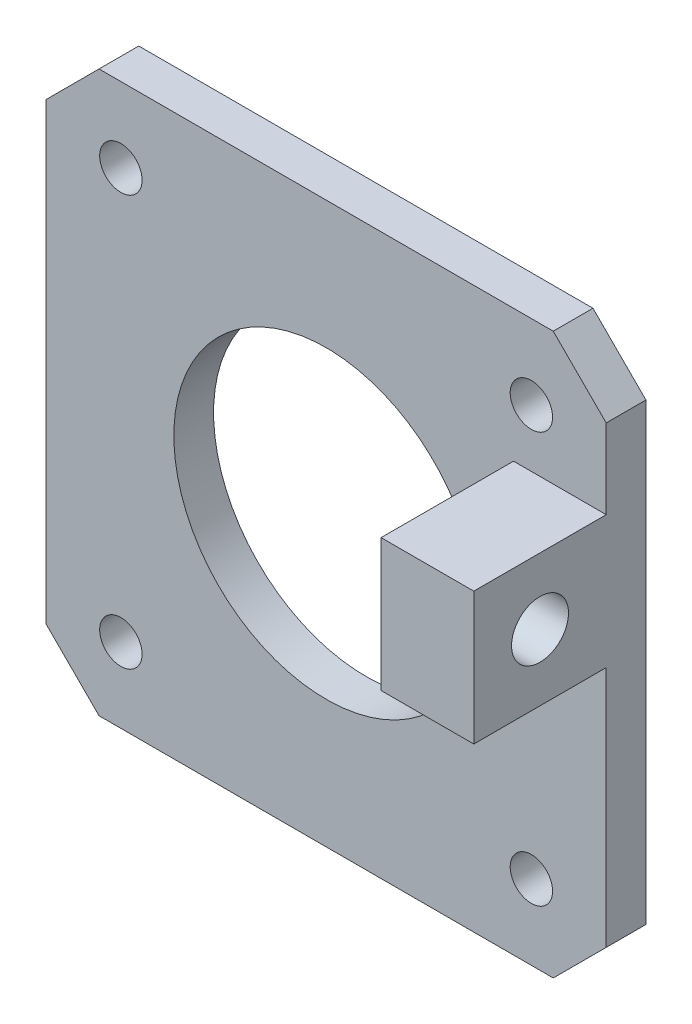
from build123d import *

# Parameters (mm, degrees)
CROQUIS1_R              = 11.5
CROQUIS1_R_2            = 1.6
SALIENTE_EXTRUIR1_DEPTH = 3
CROQUIS2_W              = 10
CROQUIS2_H              = 10
CROQUIS2_R              = 2.15
SALIENTE_EXTRUIR2_DEPTH = 7


with BuildPart() as part:
    # Croquis1 → Saliente-Extruir1 (new body)
    with BuildSketch(Plane.XY):
        Polygon((21.15, 17.15), (17.15, 21.15), (-17.15, 21.15), (-21.15, 17.15), (-21.15, -17.15), (-17.15, -21.15), (17.15, -21.15), (21.15, -17.15), align=None)
        Circle(CROQUIS1_R, mode=Mode.SUBTRACT)
        with Locations((15.5, 15.5)):
            Circle(CROQUIS1_R_2, mode=Mode.SUBTRACT)
        with Locations((15.5, -15.5)):
            Circle(CROQUIS1_R_2, mode=Mode.SUBTRACT)
        with Locations((-15.5, -15.5)):
            Circle(CROQUIS1_R_2, mode=Mode.SUBTRACT)
        with Locations((-15.5, 15.5)):
            Circle(CROQUIS1_R_2, mode=Mode.SUBTRACT)
    extrude(amount=SALIENTE_EXTRUIR1_DEPTH)

    # Croquis2 → Saliente-Extruir2 (add)
    with BuildSketch(Plane(origin=(21.15, 0, 0), x_dir=(0, 0, -1), z_dir=(1, 0, 0))):
        with Locations((-8, 6.15)):
            Rectangle(CROQUIS2_W, CROQUIS2_H)
        with Locations((-8, 6.15)):
            Circle(CROQUIS2_R, mode=Mode.SUBTRACT)
    extrude(amount=-SALIENTE_EXTRUIR2_DEPTH)


solid = part.part
